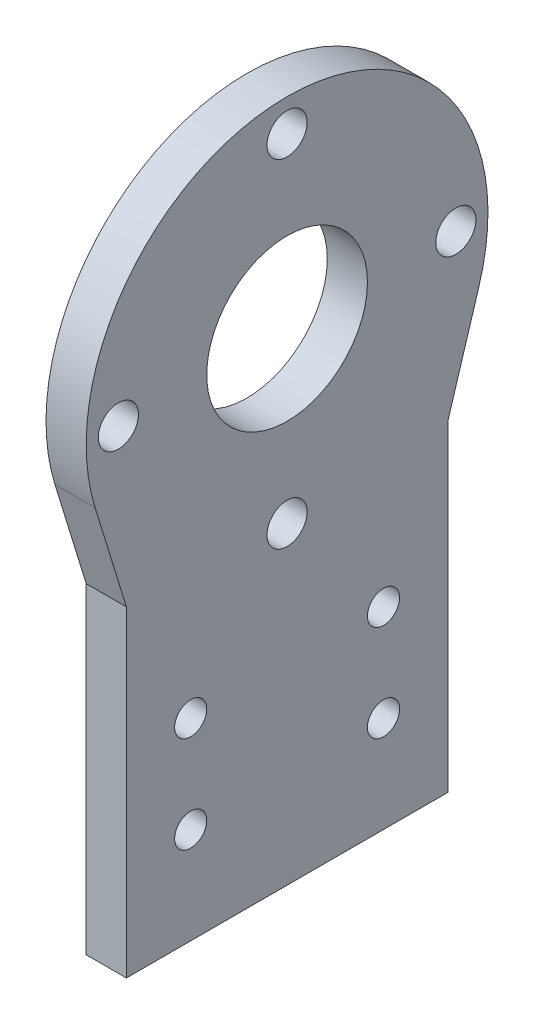
from build123d import *

# Parameters (mm, degrees)
CROQUIS1_R              = 2
CROQUIS1_R_2            = 2.5
CROQUIS1_R_3            = 10
SALIENTE_EXTRUIR1_DEPTH = 5


with BuildPart() as part:
    # Croquis1 → Saliente-Extruir1 (new body)
    with BuildSketch(Plane(origin=(0, 0, 0), x_dir=(0, 0, -1), z_dir=(1, 0, 0))):
        with BuildLine():
            ThreePointArc((43.892972847, 52.642972847), (20, 85), (-3.892972847, 52.642972847))
            Line((-3.892972847, 52.642972847), (0, 40))
            Line((0, 40), (0, 0))
            Line((0, 0), (40, 0))
            Line((40, 0), (40, 40))
            Line((40, 40), (43.892972847, 52.642972847))
        make_face()
        with Locations((8, 12)):
            Circle(CROQUIS1_R, mode=Mode.SUBTRACT)
        with Locations((8, 24)):
            Circle(CROQUIS1_R, mode=Mode.SUBTRACT)
        with Locations((20, 39)):
            Circle(CROQUIS1_R_2, mode=Mode.SUBTRACT)
        with Locations((32, 12)):
            Circle(CROQUIS1_R, mode=Mode.SUBTRACT)
        with Locations((32, 24)):
            Circle(CROQUIS1_R, mode=Mode.SUBTRACT)
        with Locations((-1, 60)):
            Circle(CROQUIS1_R_2, mode=Mode.SUBTRACT)
        with Locations((20, 60)):
            Circle(CROQUIS1_R_3, mode=Mode.SUBTRACT)
        with Locations((20, 81)):
            Circle(CROQUIS1_R_2, mode=Mode.SUBTRACT)
        with Locations((41, 60)):
            Circle(CROQUIS1_R_2, mode=Mode.SUBTRACT)
    extrude(amount=SALIENTE_EXTRUIR1_DEPTH)


solid = part.part
